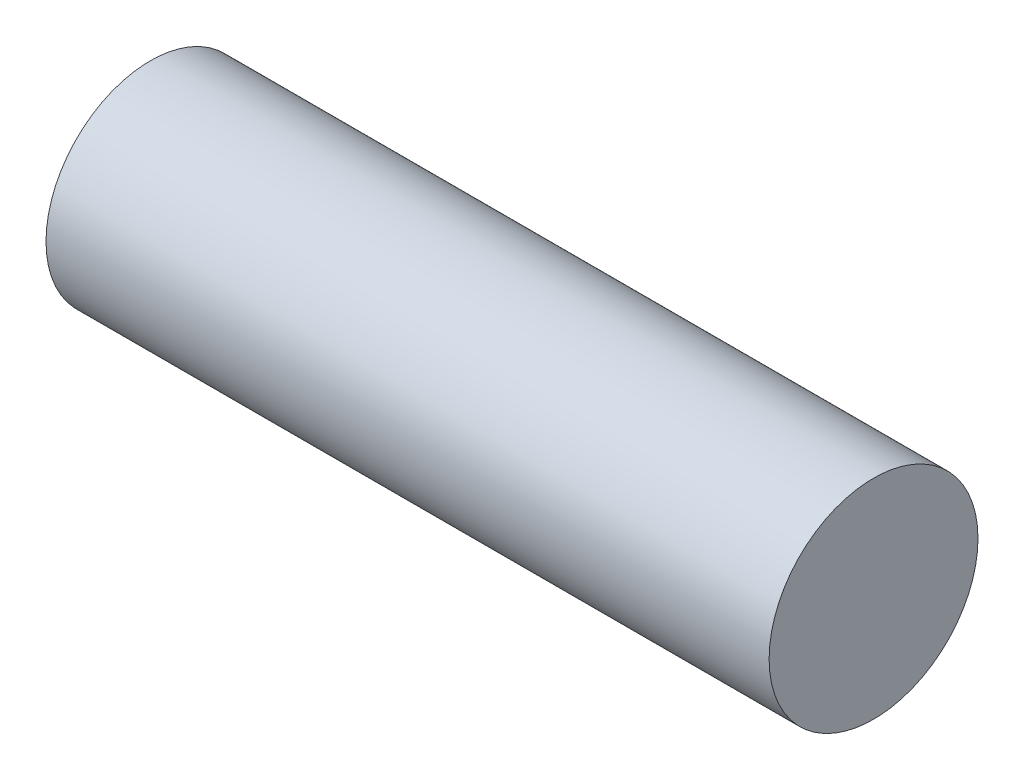
from build123d import *

# Parameters (mm, degrees)
SZKIC1_R                    = 2.6
DODANIE_WYCI_GNI_CIE1_DEPTH = 9


with BuildPart() as part:
    # Szkic1 → Dodanie-wyciągnięcie1 (new body, symmetric)
    with BuildSketch(Plane(origin=(0, 0, 0), x_dir=(0, 0, -1), z_dir=(1, 0, 0))):
        Circle(SZKIC1_R)
    extrude(amount=DODANIE_WYCI_GNI_CIE1_DEPTH, both=True)


solid = part.part
